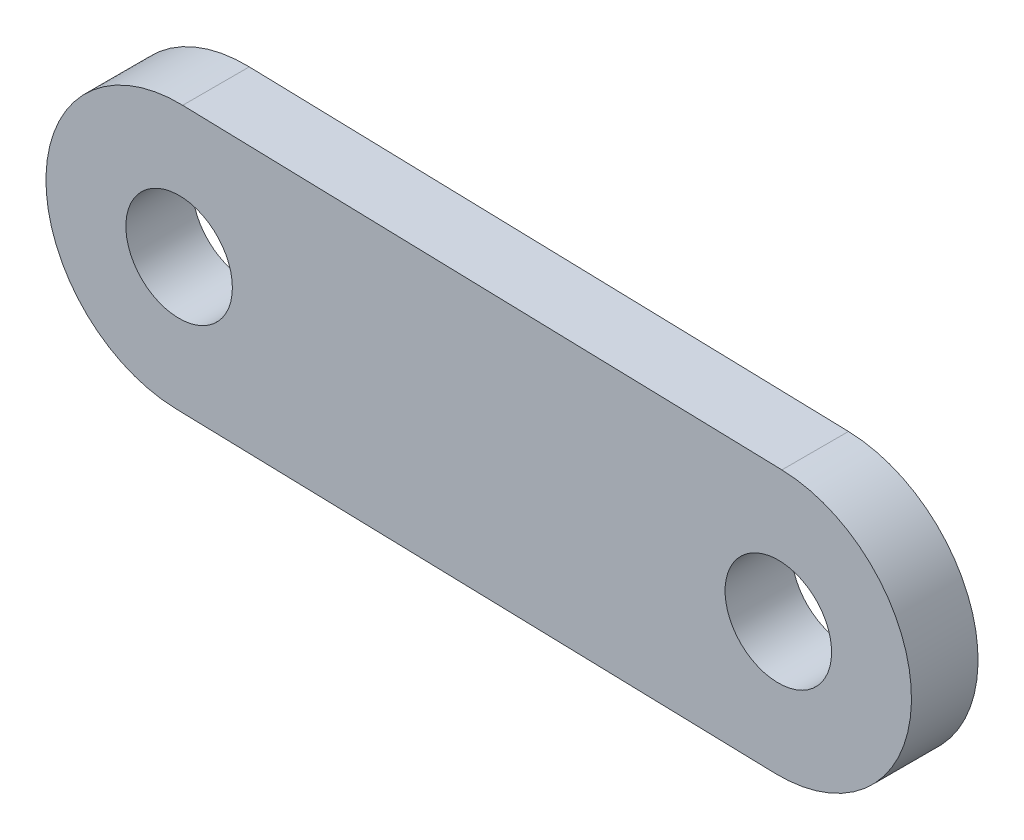
from build123d import *

# Parameters (mm, degrees)
SKETCH1_R           = 4
BOSS_EXTRUDE1_DEPTH = 5


with BuildPart() as part:
    # Sketch1 → Boss-Extrude1 (new body)
    with BuildSketch(Plane.XY):
        with BuildLine():
            Line((-22.23071963, 10.602474367), (22.76928037, 9.390273126))
            ThreePointArc((22.76928037, 9.390273126), (32.496373747, -0.875380991), (22.23071963, -10.602474367))
            Line((22.23071963, -10.602474367), (-22.76928037, -9.390273126))
            ThreePointArc((-22.76928037, -9.390273126), (-32.496373747, 0.875380991), (-22.23071963, 10.602474367))
        make_face()
        with Locations((22.5, -0.606100621)):
            Circle(SKETCH1_R, mode=Mode.SUBTRACT)
        with Locations((-22.5, 0.606100621)):
            Circle(SKETCH1_R, mode=Mode.SUBTRACT)
    extrude(amount=BOSS_EXTRUDE1_DEPTH)


solid = part.part
